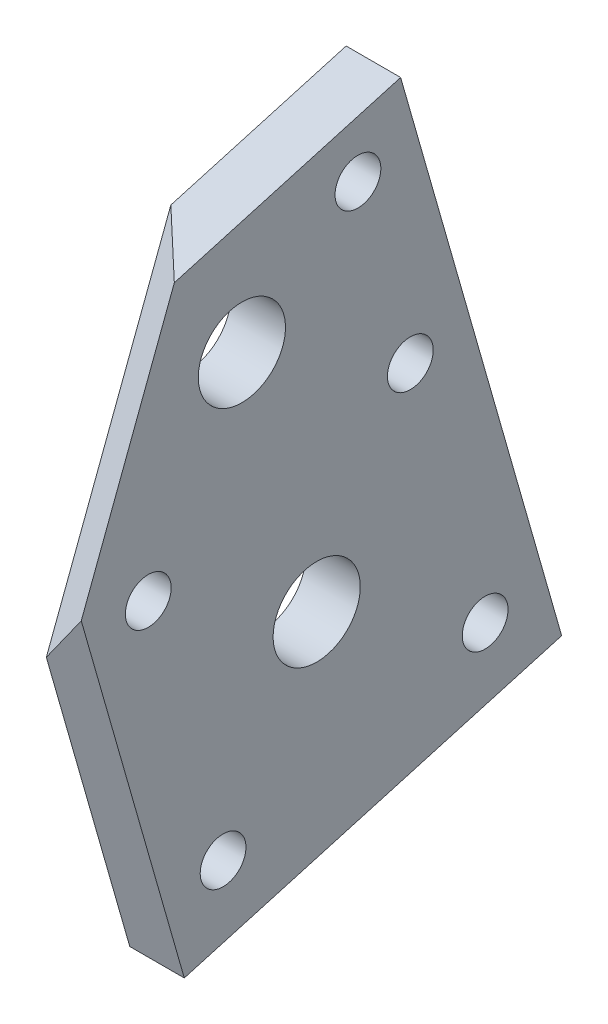
from build123d import *

# Parameters (mm, degrees)
SKETCH2_W           = 5
SKETCH2_H           = 53.8
BOSS_EXTRUDE1_DEPTH = 36
CUT_EXTRUDE1_DEPTH  = 15.943798685
SKETCH4_R           = 2.1
SKETCH4_R_2         = 4
CUT_EXTRUDE2_DEPTH  = 6


with BuildPart() as part:
    # Sketch2 → Boss-Extrude1 (new body)
    with BuildSketch(Plane(origin=(0, 629.439859668, -2204.462438001), x_dir=(1, 0, 0), z_dir=(0, -0.274557173, 0.961570777))):
        with Locations((-194.323635178, 2543.140113693)):
            Rectangle(SKETCH2_W, SKETCH2_H)
    extrude(amount=BOSS_EXTRUDE1_DEPTH)

    # Sketch3 → Cut-Extrude1 (cut, through all)
    with BuildSketch(Plane(origin=(67.333864744, -30.465363781, -80.619122615), x_dir=(0.491076421, 0.867206701, 0.082440809), z_dir=(0.615661475, -0.278557467, -0.737134103))):
        Polygon((2395.145764251, -2402.321354937), (2500.725824186, -2486.45131954), (2658.658473348, -2288.251562261), (2553.078413412, -2204.121597658), align=None)
    extrude(amount=-CUT_EXTRUDE1_DEPTH, mode=Mode.SUBTRACT)

    # Sketch4 → Cut-Extrude2 (cut, through all)
    with BuildSketch(Plane.ZY.offset(196.823635178)):
        with Locations((-1506.592316509, 3053.530651846)):
            Circle(SKETCH4_R)
        with Locations((-1482.553047089, 3046.666722522)):
            Circle(SKETCH4_R)
        with Locations((-1499.728387186, 3077.569921266)):
            Circle(SKETCH4_R)
        with Locations((-1475.689117766, 3070.705991942)):
            Circle(SKETCH4_R)
        with Locations((-1470.88436724, 3087.533480536)):
            Circle(SKETCH4_R)
        with Locations((-1494.92363666, 3094.397409859)):
            Circle(SKETCH4_R)
        with Locations((-1484.276787814, 3086.157591314)):
            Circle(SKETCH4_R_2)
        with Locations((-1491.140717138, 3062.118321894)):
            Circle(SKETCH4_R_2)
    extrude(amount=-CUT_EXTRUDE2_DEPTH, mode=Mode.SUBTRACT)


solid = part.part
